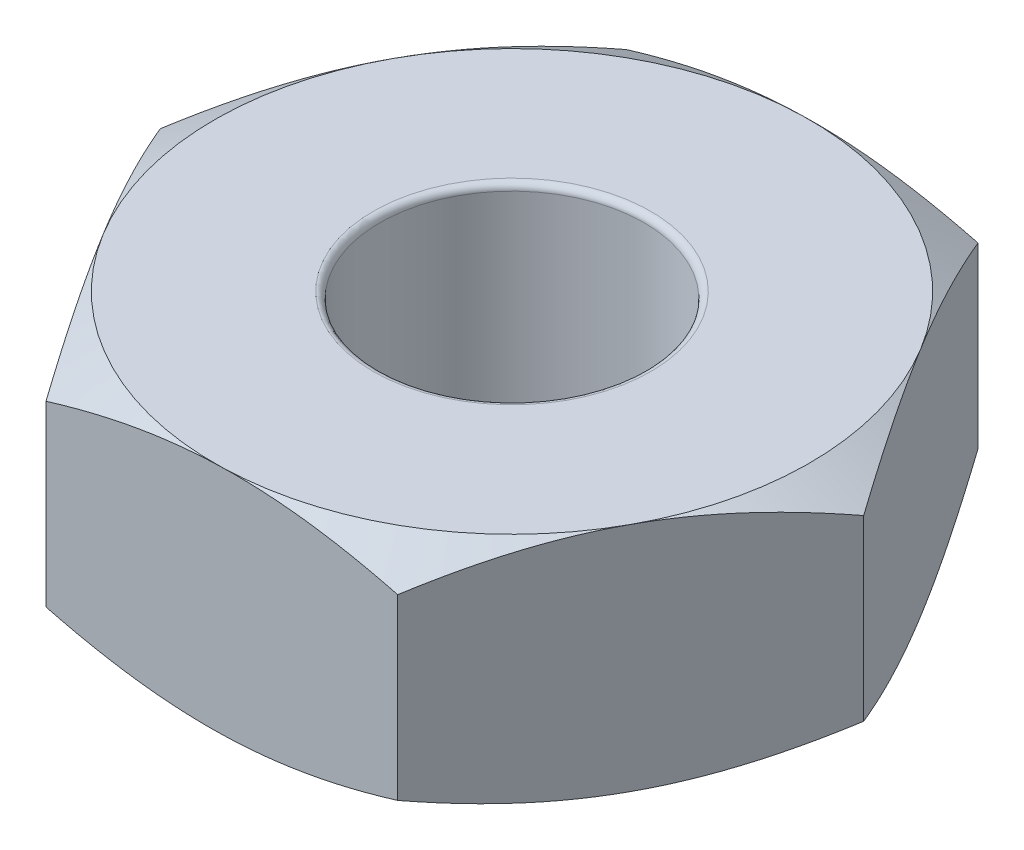
from build123d import *

# Parameters (mm, degrees)
SKETCH1_R           = 1
BOSS_EXTRUDE1_DEPTH = 1.75
SKETCH3_OUTSIDE_W   = 14.682
SKETCH3_OUTSIDE_H   = 14.05
SKETCH3_OUTSIDE_R   = 2.25
CUT_EXTRUDE2_DEPTH  = 1.75
CUT_EXTRUDE2_TAPER  = 60
SKETCH4_OUTSIDE_W   = 14.682
SKETCH4_OUTSIDE_H   = 14.05
SKETCH4_OUTSIDE_R   = 2.25
CUT_EXTRUDE3_DEPTH  = 1.75
CUT_EXTRUDE3_TAPER  = 60
FILLET1_R           = 0.05


with BuildPart() as part:
    # Sketch1 → Boss-Extrude1 (new body)
    with BuildSketch(Plane(origin=(0, 0, 0), x_dir=(1, 0, 0), z_dir=(0, 1, 0))):
        Polygon((1.353165533, -2.217869032), (2.59731369, 0.062941211), (1.244148157, 2.280810243), (-1.353165533, 2.217869032), (-2.59731369, -0.062941211), (-1.244148157, -2.280810243), align=None)
        Circle(SKETCH1_R, mode=Mode.SUBTRACT)
    extrude(amount=BOSS_EXTRUDE1_DEPTH)

    # Sketch3 outside → Cut-Extrude2 (cut)
    with BuildSketch(Plane(origin=(0, 1.75, 0), x_dir=(1, 0, 0), z_dir=(0, 1, 0))):
        Rectangle(SKETCH3_OUTSIDE_W, SKETCH3_OUTSIDE_H)
        Circle(SKETCH3_OUTSIDE_R, mode=Mode.SUBTRACT)
    extrude(amount=-CUT_EXTRUDE2_DEPTH, taper=CUT_EXTRUDE2_TAPER, mode=Mode.SUBTRACT)

    # Sketch4 outside → Cut-Extrude3 (cut)
    with BuildSketch(Plane.XZ):
        Rectangle(SKETCH4_OUTSIDE_W, SKETCH4_OUTSIDE_H)
        Circle(SKETCH4_OUTSIDE_R, mode=Mode.SUBTRACT)
    extrude(amount=-CUT_EXTRUDE3_DEPTH, taper=CUT_EXTRUDE3_TAPER, mode=Mode.SUBTRACT)

    # Fillet1
    fillet1_edges = [part.edges().sort_by_distance(p)[0] for p in [
        (-1, 0, 0),
        (-1, 1.75, 0),
    ]]
    fillet(fillet1_edges, radius=FILLET1_R)


solid = part.part
